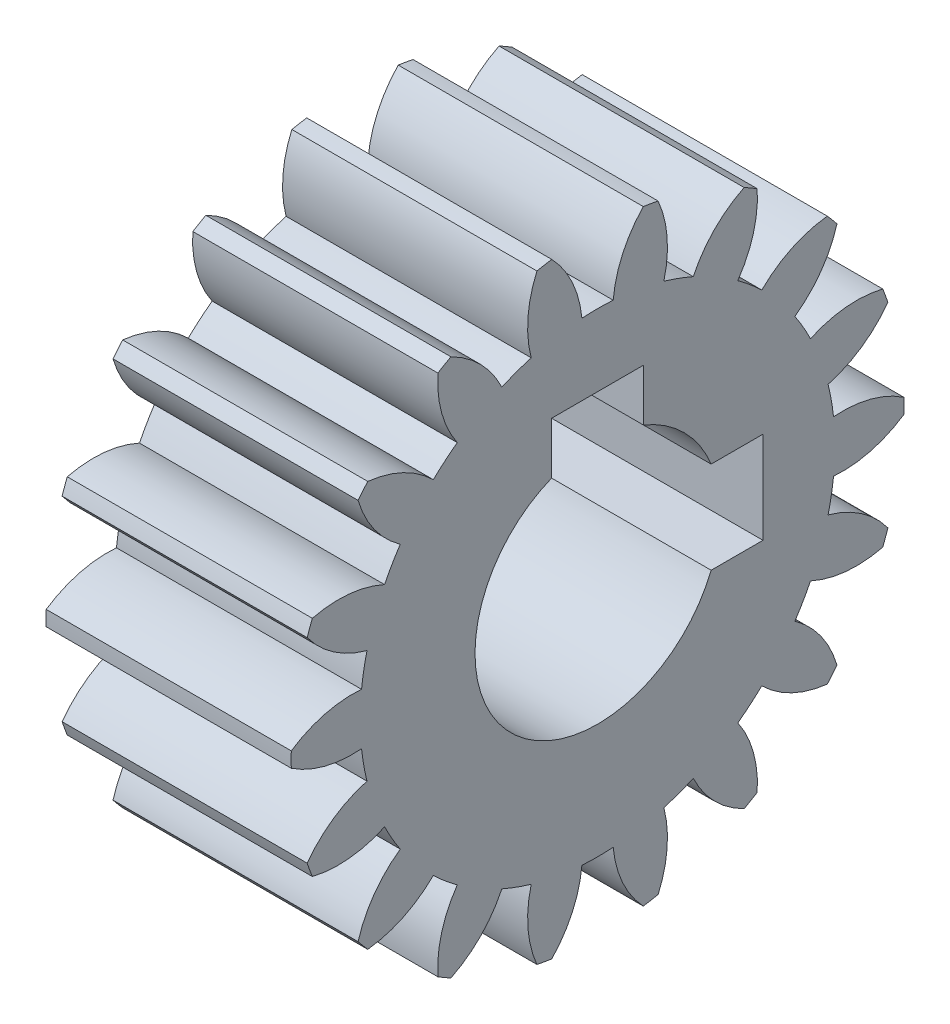
from build123d import *

# Parameters (mm, degrees)
BASPROSKE_W     = 8
BASPROSKE_H     = 10
TOOTHCUT_DEPTH  = 17.248076809
TEETHCUTS_COUNT = 18
TEETHCUTS_ANGLE = 340
BORSKE_R        = 4
BORE_DEPTH      = 50.0000508
KEYSKE_W        = 3
KEYSKE_H        = 5.4
KEYWAY_DEPTH    = 50.0000508
KEYWAY2_COUNT   = 2
KEYWAY2_ANGLE   = 90


with BuildPart() as part:
    # BasProSke → Base-Revolve (revolve)
    with BuildSketch(Plane(origin=(0, 0, 0), x_dir=(1, 0, 0), z_dir=(0, 1, 0)), mode=Mode.PRIVATE) as base_revolve_sk:
        with Locations((4, 5)):
            Rectangle(BASPROSKE_W, BASPROSKE_H)
    revolve(base_revolve_sk.sketch.rotate(Axis((-10, 0, 0), (1, 0, 0)), 180), axis=Axis((-10, 0, 0), (1, 0, 0)))

    # TooCutSke → ToothCut (cut, through all)
    with BuildSketch(Plane(origin=(0, 0, 0), x_dir=(0, 0, -1), z_dir=(1, 0, 0))):
        with BuildLine():
            ThreePointArc((0.510641536, 7.732156635), (0, 7.749), (-0.510641536, 7.732156635))
            ThreePointArc((-0.510641536, 7.732156635), (-0.82619259, 8.907320741), (-1.515208602, 9.910236529))
            ThreePointArc((-1.515208602, 9.910236529), (0, 10.0254), (1.515208602, 9.910236529))
            ThreePointArc((1.515208602, 9.910236529), (0.82619259, 8.907320741), (0.510641536, 7.732156635))
        make_face()
    toothcut = extrude(amount=TOOTHCUT_DEPTH, mode=Mode.SUBTRACT)

    # TeethCuts: ToothCut ×18 about axis
    teethcuts_axis = Axis((-10, 0, 0), (1, 0, 0))
    for i in range(1, TEETHCUTS_COUNT):
        add(toothcut.rotate(teethcuts_axis, i * TEETHCUTS_ANGLE / (TEETHCUTS_COUNT - 1)), mode=Mode.SUBTRACT)

    # BorSke → Bore (cut, symmetric)
    with BuildSketch(Plane(origin=(0, 0, 0), x_dir=(0, 0, -1), z_dir=(1, 0, 0))):
        with Locations(Location((0, 0, 0), (0, 0, 180))):
            Circle(BORSKE_R)
    extrude(amount=BORE_DEPTH, both=True, mode=Mode.SUBTRACT)

    # KeySke → Keyway (cut, symmetric)
    with BuildSketch(Plane(origin=(0, 0, 0), x_dir=(0, 0, -1), z_dir=(1, 0, 0))):
        with Locations((0, 2.7)):
            Rectangle(KEYSKE_W, KEYSKE_H)
    keyway = extrude(amount=KEYWAY_DEPTH, both=True, mode=Mode.SUBTRACT)

    # Keyway2: Keyway ×2 about axis
    keyway2_axis = Axis((0, 0, 0), (-1, 0, 0))
    for i in range(1, KEYWAY2_COUNT):
        add(keyway.rotate(keyway2_axis, i * KEYWAY2_ANGLE / (KEYWAY2_COUNT - 1)), mode=Mode.SUBTRACT)


solid = part.part
